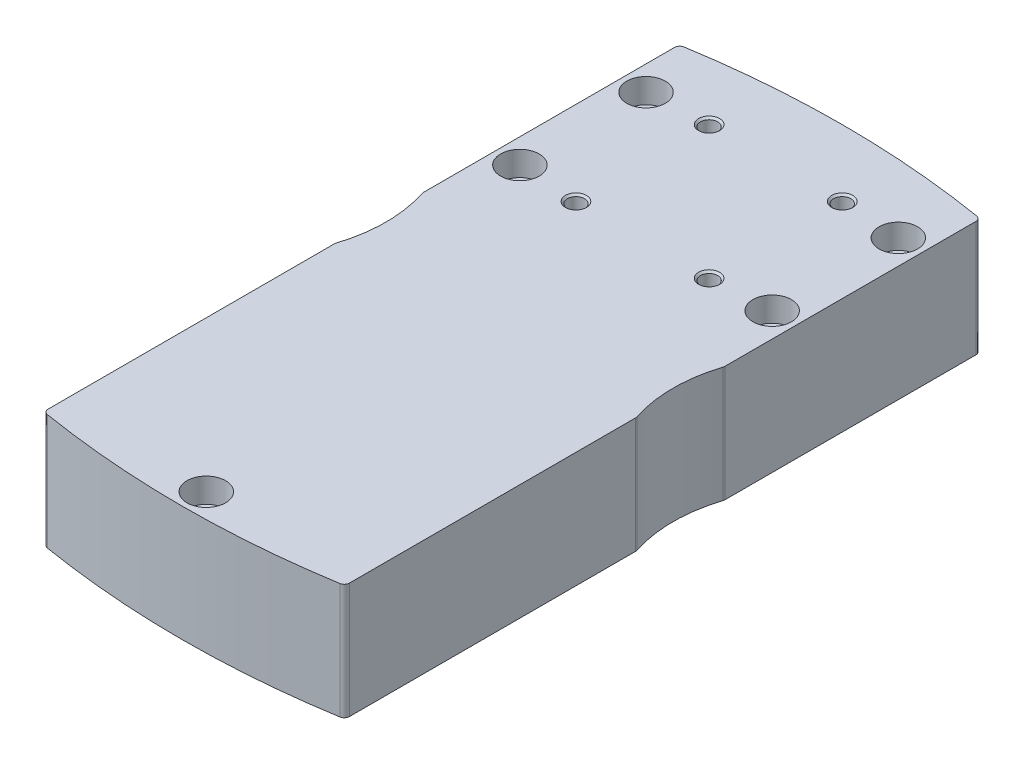
from build123d import *

# Parameters (mm, degrees)
BOSS_EXTRUDE1_DEPTH = 33
CUT_EXTRUDE1_DEPTH  = 29
CUT_EXTRUDE2_DEPTH  = 10
CUT_EXTRUDE3_DEPTH  = 3


with BuildPart() as part:
    # Sketch1 → Boss-Extrude1 (new body)
    with BuildSketch(Plane(origin=(0, 0, 0), x_dir=(1, 0, 0), z_dir=(0, 1, 0))):
        with BuildLine():
            Line((-43, 86.522077939), (-43, 4.879475348))
            ThreePointArc((-43, 4.879475348), (-42.64324868, 3.90840251), (-41.742690058, 3.399238362))
            ThreePointArc((-41.742690058, 3.399238362), (0, 0), (41.742690058, 3.399238362))
            ThreePointArc((41.742690058, 3.399238362), (42.64324868, 3.90840251), (43, 4.879475348))
            Line((43, 4.879475348), (43, 86.522077939))
            ThreePointArc((43, 86.522077939), (42.98181751, 86.754923096), (42.927710843, 86.982123314))
            ThreePointArc((42.927710843, 86.982123314), (41, 99.25), (42.927710843, 111.517876686))
            ThreePointArc((42.927710843, 111.517876686), (42.98181751, 111.745076904), (43, 111.977922061))
            Line((43, 111.977922061), (43, 183.620524652))
            ThreePointArc((43, 183.620524652), (42.64324868, 184.59159749), (41.742690058, 185.100761638))
            ThreePointArc((41.742690058, 185.100761638), (0, 188.5), (-41.742690058, 185.100761638))
            ThreePointArc((-41.742690058, 185.100761638), (-42.64324868, 184.59159749), (-43, 183.620524652))
            Line((-43, 183.620524652), (-43, 111.977922061))
            ThreePointArc((-43, 111.977922061), (-42.98181751, 111.745076904), (-42.927710843, 111.517876686))
            ThreePointArc((-42.927710843, 111.517876686), (-41, 99.25), (-42.927710843, 86.982123314))
            ThreePointArc((-42.927710843, 86.982123314), (-42.98181751, 86.754923096), (-43, 86.522077939))
        make_face()
    extrude(amount=BOSS_EXTRUDE1_DEPTH)

    # Sketch2 → Cut-Extrude1 (cut)
    with BuildSketch(Plane(origin=(0, 0, 0), x_dir=(1, 0, 0), z_dir=(0, 1, 0))):
        with BuildLine():
            Line((27.5, 62.274102424), (27.5, 101.284609691))
            ThreePointArc((27.5, 101.284609691), (27.091109915, 104.390438232), (25.892304845, 107.284609691))
            Line((25.892304845, 107.284609691), (16.107695155, 124.232050808))
            ThreePointArc((16.107695155, 124.232050808), (14.908890085, 127.126222266), (14.5, 130.232050808))
            Line((14.5, 130.232050808), (14.5, 166))
            ThreePointArc((14.5, 166), (0, 180.5), (-14.5, 166))
            Line((-14.5, 166), (-14.5, 130.232050808))
            ThreePointArc((-14.5, 130.232050808), (-14.908890085, 127.126222266), (-16.107695155, 124.232050808))
            Line((-16.107695155, 124.232050808), (-25.892304845, 107.284609691))
            ThreePointArc((-25.892304845, 107.284609691), (-27.091109915, 104.390438232), (-27.5, 101.284609691))
            Line((-27.5, 101.284609691), (-27.5, 62.274102424))
            ThreePointArc((-27.5, 62.274102424), (-27.679920232, 60.203905746), (-28.214285714, 58.195787445))
            ThreePointArc((-28.214285714, 58.195787445), (0, 18), (28.214285714, 58.195787445))
            ThreePointArc((28.214285714, 58.195787445), (27.679920232, 60.203905746), (27.5, 62.274102424))
        make_face()
    extrude(amount=CUT_EXTRUDE1_DEPTH, mode=Mode.SUBTRACT)

    # Sketch3 → Cut-Extrude2 (cut)
    with BuildSketch(Plane(origin=(0, 0, 0), x_dir=(1, 0, 0), z_dir=(0, 1, 0))):
        with BuildLine():
            ThreePointArc((-15.303206241, 170.268962511), (0, 125.5), (15.303206241, 170.268962511))
            ThreePointArc((15.303206241, 170.268962511), (13.698371822, 171.764891444), (12.392709657, 173.527997565))
            ThreePointArc((12.392709657, 173.527997565), (0, 180.5), (-12.392709657, 173.527997565))
            ThreePointArc((-12.392709657, 173.527997565), (-13.698371822, 171.764891444), (-15.303206241, 170.268962511))
        make_face()
    extrude(amount=CUT_EXTRUDE2_DEPTH, mode=Mode.SUBTRACT)

    # Sketch4 → Cut-Extrude3 (cut)
    with BuildSketch(Plane(origin=(0, 0, 0), x_dir=(1, 0, 0), z_dir=(0, 1, 0))):
        with BuildLine():
            Line((27.5, 61.919410907), (27.5, 136.580589093))
            ThreePointArc((27.5, 136.580589093), (27.657490157, 138.348356046), (28.125, 140.06044182))
            ThreePointArc((28.125, 140.06044182), (0, 180.5), (-28.125, 140.06044182))
            ThreePointArc((-28.125, 140.06044182), (-27.657490157, 138.348356046), (-27.5, 136.580589093))
            Line((-27.5, 136.580589093), (-27.5, 61.919410907))
            ThreePointArc((-27.5, 61.919410907), (-27.657490157, 60.151643954), (-28.125, 58.43955818))
            ThreePointArc((-28.125, 58.43955818), (0, 18), (28.125, 58.43955818))
            ThreePointArc((28.125, 58.43955818), (27.657490157, 60.151643954), (27.5, 61.919410907))
        make_face()
    extrude(amount=CUT_EXTRUDE3_DEPTH, mode=Mode.SUBTRACT)

    # Sketch5 → Cut-Revolve1 (revolve, cut)
    with BuildSketch(Plane(origin=(0, 0, 0), x_dir=(0, 0, -1), z_dir=(1, 0, 0))):
        Polygon((7, 33), (12.5, 33), (12.5, 26), (10.3, 26), (10.3, 0), (7, 0), align=None)
    revolve(axis=Axis((0, 0, -7), (0, 1, 0)), mode=Mode.SUBTRACT)

    # Sketch6 → Cut-Revolve2 (revolve, cut)
    with BuildSketch(Plane(origin=(36, 0, 0), x_dir=(0, 0, -1), z_dir=(1, 0, 0))):
        Polygon((132.5, 33), (138, 33), (138, 26), (135.8, 26), (135.8, 0), (132.5, 0), align=None)
    revolve(axis=Axis((36, 0, -132.5), (0, 1, 0)), mode=Mode.SUBTRACT)

    # Sketch7 → Cut-Revolve3 (revolve, cut)
    with BuildSketch(Plane(origin=(36, 0, 0), x_dir=(0, 0, -1), z_dir=(1, 0, 0))):
        Polygon((168.5, 33), (174, 33), (174, 26), (171.8, 26), (171.8, 0), (168.5, 0), align=None)
    revolve(axis=Axis((36, 0, -168.5), (0, 1, 0)), mode=Mode.SUBTRACT)

    # Sketch8 → Cut-Revolve4 (revolve, cut)
    with BuildSketch(Plane(origin=(-36, 0, 0), x_dir=(0, 0, -1), z_dir=(1, 0, 0))):
        Polygon((132.5, 33), (138, 33), (138, 26), (135.8, 26), (135.8, 0), (132.5, 0), align=None)
    revolve(axis=Axis((-36, 0, -132.5), (0, 1, 0)), mode=Mode.SUBTRACT)

    # Sketch9 → Cut-Revolve5 (revolve, cut)
    with BuildSketch(Plane(origin=(-36, 0, 0), x_dir=(0, 0, -1), z_dir=(1, 0, 0))):
        Polygon((168.5, 33), (174, 33), (174, 26), (171.8, 26), (171.8, 0), (168.5, 0), align=None)
    revolve(axis=Axis((-36, 0, -168.5), (0, 1, 0)), mode=Mode.SUBTRACT)

    # Sketch10 → Cut-Revolve6 (revolve, cut)
    with BuildSketch(Plane.XY.offset(-169.5)):
        Polygon((19, 33), (22, 33), (21.4585, 32.4585), (21.4585, 14), (19, 12.580584363), align=None)
    revolve(axis=Axis((19, 12.580584363, -169.5), (0, 1, 0)), mode=Mode.SUBTRACT)

    # Sketch11 → Cut-Revolve7 (revolve, cut)
    with BuildSketch(Plane.XY.offset(-169.5)):
        Polygon((-19, 33), (-16, 33), (-16.5415, 32.4585), (-16.5415, 14), (-19, 12.580584363), align=None)
    revolve(axis=Axis((-19, 12.580584363, -169.5), (0, 1, 0)), mode=Mode.SUBTRACT)

    # Sketch12 → Cut-Revolve8 (revolve, cut)
    with BuildSketch(Plane.XY.offset(-131.5)):
        Polygon((19, 33), (22, 33), (21.4585, 32.4585), (21.4585, 14), (19, 12.580584363), align=None)
    revolve(axis=Axis((19, 12.580584363, -131.5), (0, 1, 0)), mode=Mode.SUBTRACT)

    # Sketch13 → Cut-Revolve9 (revolve, cut)
    with BuildSketch(Plane.XY.offset(-131.5)):
        Polygon((-19, 33), (-16, 33), (-16.5415, 32.4585), (-16.5415, 14), (-19, 12.580584363), align=None)
    revolve(axis=Axis((-19, 12.580584363, -131.5), (0, 1, 0)), mode=Mode.SUBTRACT)


solid = part.part
